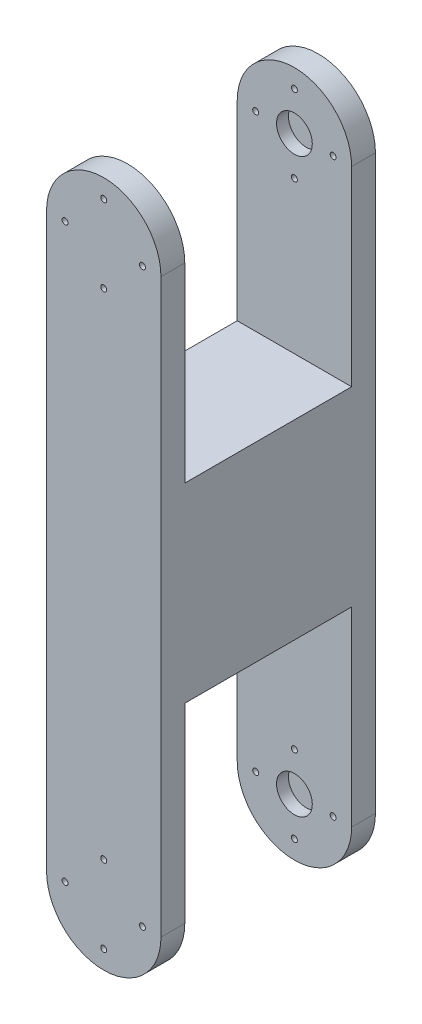
from build123d import *

# Parameters (mm, degrees)
BOSS_EXTRUDE1_DEPTH = 57.15
SKETCH2_W           = 44.45
SKETCH2_H           = 66.04
CUT_EXTRUDE1_DEPTH  = 57.15
SKETCH6_R           = 4.7625
CUT_EXTRUDE3_DEPTH  = 3.175
SKETCH8_R           = 0.79375
CUT_EXTRUDE4_DEPTH  = 58.15


with BuildPart() as part:
    # Sketch1 → Boss-Extrude1 (new body)
    with BuildSketch(Plane.XY):
        with BuildLine():
            Line((-15.24, 76.2), (-15.24, -76.2))
            ThreePointArc((-15.24, -76.2), (0, -91.44), (15.24, -76.2))
            Line((15.24, -76.2), (15.24, 76.2))
            ThreePointArc((15.24, 76.2), (0, 91.44), (-15.24, 76.2))
        make_face()
    extrude(amount=BOSS_EXTRUDE1_DEPTH)

    # Sketch2 → Cut-Extrude1 (cut)
    with BuildSketch(Plane(origin=(15.24, 0, 0), x_dir=(0, 0, -1), z_dir=(1, 0, 0))):
        with Locations((-28.575, 58.42)):
            Rectangle(SKETCH2_W, SKETCH2_H)
    cut_extrude1 = extrude(amount=-CUT_EXTRUDE1_DEPTH, mode=Mode.SUBTRACT)

    # Sketch6 → Cut-Extrude3 (cut)
    with BuildSketch(Plane.XY.offset(6.35)):
        with Locations((0, 76.2)):
            Circle(SKETCH6_R)
    cut_extrude3 = extrude(amount=-CUT_EXTRUDE3_DEPTH, mode=Mode.SUBTRACT)

    # Mirror3: Cut-Extrude3 across plane
    add(cut_extrude3.mirror(Plane.XY.offset(28.575)), mode=Mode.SUBTRACT)

    # Sketch8 → Cut-Extrude4 (cut, through all)
    with BuildSketch(Plane(origin=(0, 0, 0), x_dir=(-1, 0, 0), z_dir=(0, 0, -1))):
        with Locations((0, 65.88125)):
            Circle(SKETCH8_R)
        with Locations((-10.31875, 76.2)):
            Circle(SKETCH8_R)
        with Locations((0, 86.51875)):
            Circle(SKETCH8_R)
        with Locations((10.31875, 76.2)):
            Circle(SKETCH8_R)
    cut_extrude4 = extrude(amount=-CUT_EXTRUDE4_DEPTH, mode=Mode.SUBTRACT)

    # Mirror7: Cut-Extrude1, Cut-Extrude3, Cut-Extrude4 across plane
    add(cut_extrude1.mirror(Plane.ZX), mode=Mode.SUBTRACT)
    add(cut_extrude3.mirror(Plane.ZX), mode=Mode.SUBTRACT)
    add(cut_extrude4.mirror(Plane.ZX), mode=Mode.SUBTRACT)


solid = part.part
